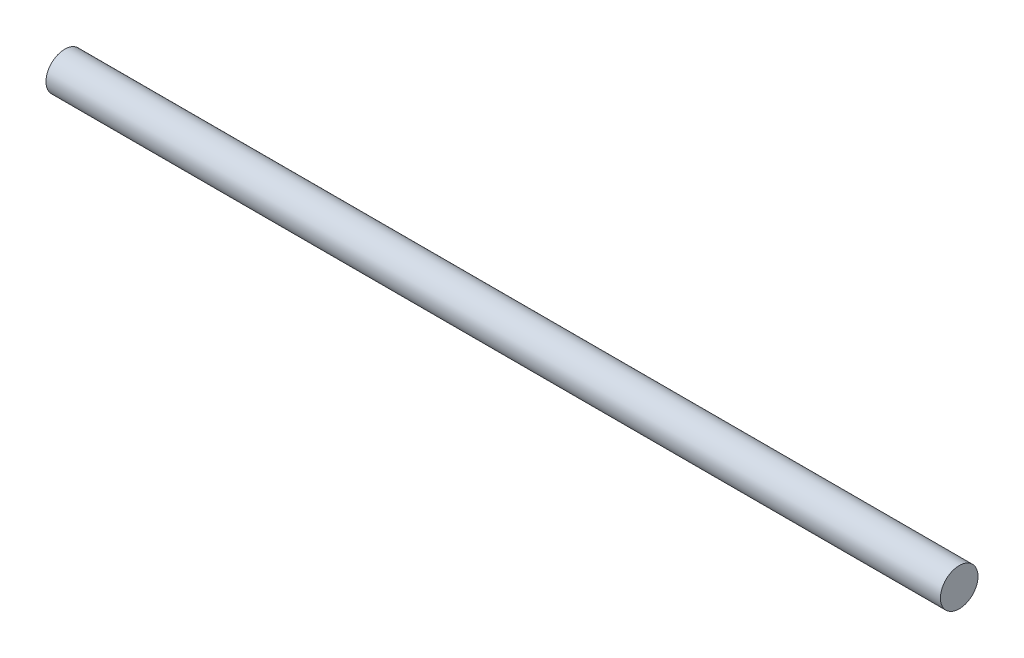
from build123d import *

# Parameters (mm, degrees)
SKETCH1_R           = 6.25
BOSS_EXTRUDE1_DEPTH = 148.75


with BuildPart() as part:
    # Sketch1 → Boss-Extrude1 (new body, symmetric)
    with BuildSketch(Plane(origin=(0, 0, 0), x_dir=(0, 0, -1), z_dir=(1, 0, 0))):
        Circle(SKETCH1_R)
    extrude(amount=BOSS_EXTRUDE1_DEPTH, both=True)


solid = part.part
